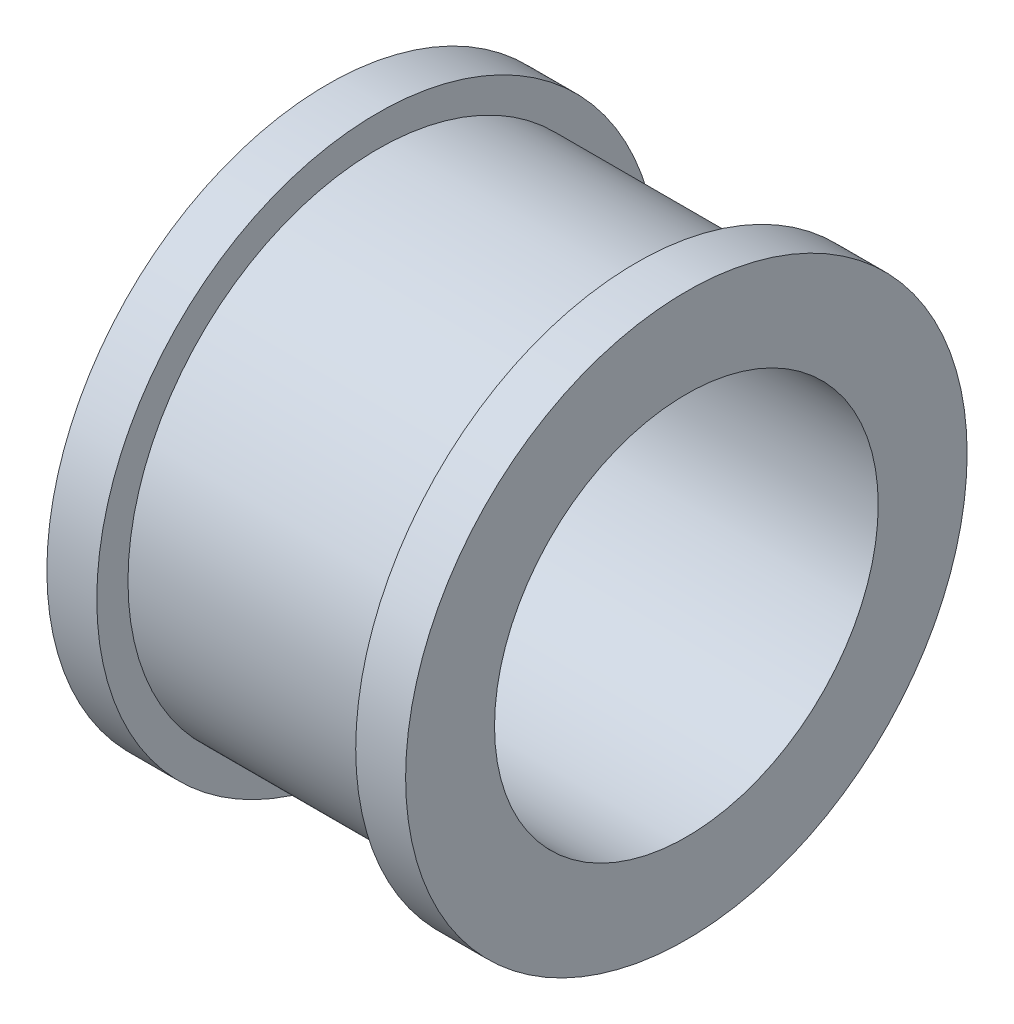
from build123d import *

# Parameters (mm, degrees)
SKETCH3_R               = 3.075
CUT_EXTRUDE1_DEPTH      = 3.875
CUT_EXTRUDE1_DEPTH_BACK = 3.875


with BuildPart() as part:
    # Sketch1 → Revolve1 (revolve)
    with BuildSketch(Plane.XY):
        Polygon((-2.875, 1.5), (-2.875, 4.5), (-2.075, 4.5), (-2.075, 4), (2.075, 4), (2.075, 4.5), (2.875, 4.5), (2.875, 1.5), align=None)
    revolve(axis=Axis((0, 0, 0), (1, 0, 0)))

    # Sketch3 → Cut-Extrude1 (cut, two sides)
    with BuildSketch(Plane(origin=(0, 0, 0), x_dir=(0, 0, -1), z_dir=(1, 0, 0))) as cut_extrude1_sk:
        Circle(SKETCH3_R)
    extrude(amount=CUT_EXTRUDE1_DEPTH, mode=Mode.SUBTRACT)
    extrude(cut_extrude1_sk.sketch, amount=-CUT_EXTRUDE1_DEPTH_BACK, mode=Mode.SUBTRACT)


solid = part.part
